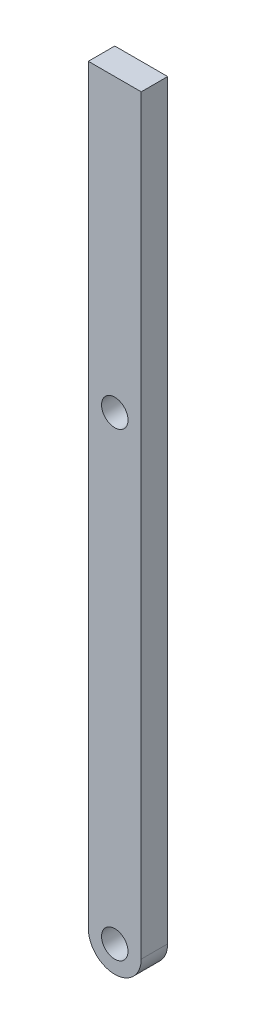
from build123d import *

# Parameters (mm, degrees)
SKETCH1_R           = 3.175
BOSS_EXTRUDE1_DEPTH = 6.35


with BuildPart() as part:
    # Sketch1 → Boss-Extrude1 (new body)
    with BuildSketch(Plane.XY):
        with BuildLine():
            Line((-6.35, 110.49), (-6.35, 0))
            ThreePointArc((-6.35, 0), (0, -6.35), (6.35, 0))
            Line((6.35, 0), (6.35, 110.49))
            Line((6.35, 110.49), (6.35, 180.34))
            Line((6.35, 180.34), (-6.35, 180.34))
            Line((-6.35, 180.34), (-6.35, 110.49))
        make_face()
        with Locations((0, 110.49)):
            Circle(SKETCH1_R, mode=Mode.SUBTRACT)
        Circle(SKETCH1_R, mode=Mode.SUBTRACT)
    extrude(amount=BOSS_EXTRUDE1_DEPTH)


solid = part.part
